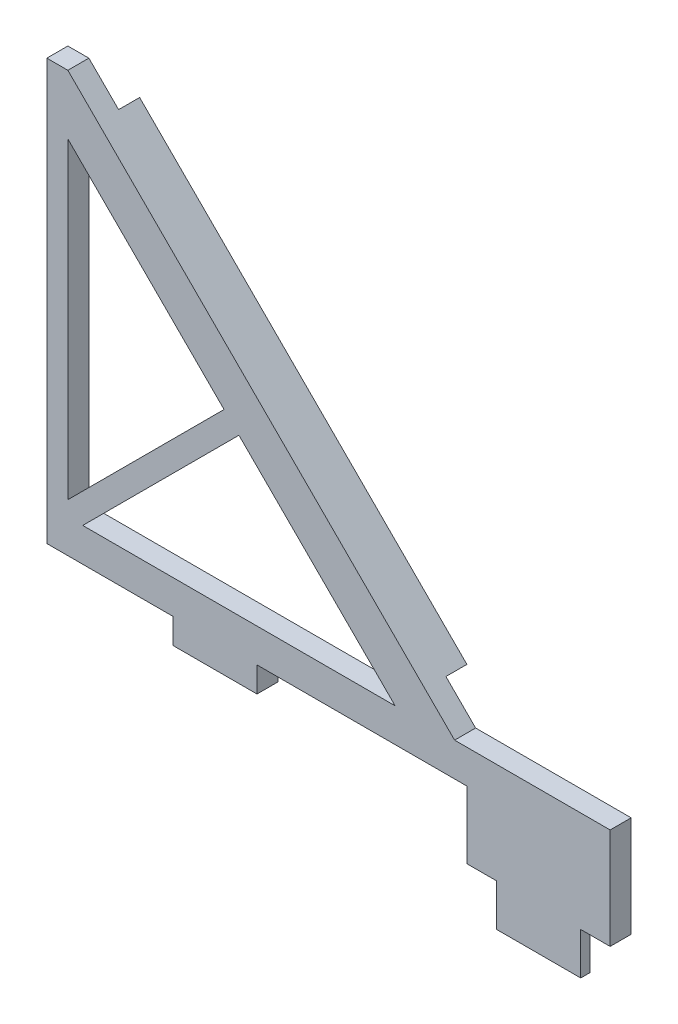
from build123d import *

# Parameters (mm, degrees)
BOSS_EXTRUDE1_DEPTH = 3.175
SKETCH3_W           = 12.7
SKETCH3_H           = 6.35
CUT_EXTRUDE1_DEPTH  = 1.778
BOSS_EXTRUDE2_DEPTH = 3.175


with BuildPart() as part:
    # Sketch2 → Boss-Extrude1 (new body)
    with BuildSketch(Plane.XY):
        Polygon((0, 0), (12.7, 0), (12.7, 6.35), (17.145, 6.35), (17.145, 21.59), (-6.35, 21.59), (-64.77, 80.01), (-67.945, 80.01), (-67.945, 16.51), (-48.895, 16.51), (-48.895, 12.7), (-36.195, 12.7), (-36.195, 16.51), (-4.445, 16.51), (-4.445, 6.35), (0, 6.35), align=None)
        Polygon((-64.77, 71.029743879), (-64.77, 23.83506403), (-41.172660076, 47.432403955), align=None, mode=Mode.SUBTRACT)
        Polygon((-62.52493597, 21.59), (-15.330256121, 21.59), (-38.927596045, 45.187339924), align=None, mode=Mode.SUBTRACT)
    extrude(amount=BOSS_EXTRUDE1_DEPTH)

    # Sketch3 → Cut-Extrude1 (cut)
    with BuildSketch(Plane(origin=(0, 0, 0), x_dir=(-1, 0, 0), z_dir=(0, 0, -1))):
        with Locations((-6.35, 3.175)):
            Rectangle(SKETCH3_W, SKETCH3_H)
    extrude(amount=-CUT_EXTRUDE1_DEPTH, mode=Mode.SUBTRACT)

    # Sketch4 → Boss-Extrude2 (add)
    with BuildSketch(Plane(origin=(0, 0, 0), x_dir=(-1, 0, 0), z_dir=(0, 0, -1))):
        Polygon((15.330256121, 21.59), (64.77, 71.029743879), (62.929047495, 72.870696384), (13.489303616, 23.430952505), align=None)
        Polygon((10.840128061, 26.080128061), (12.681080565, 24.239175556), (62.120824444, 73.678919435), (60.279871939, 75.519871939), align=None)
    extrude(amount=BOSS_EXTRUDE2_DEPTH)


solid = part.part
